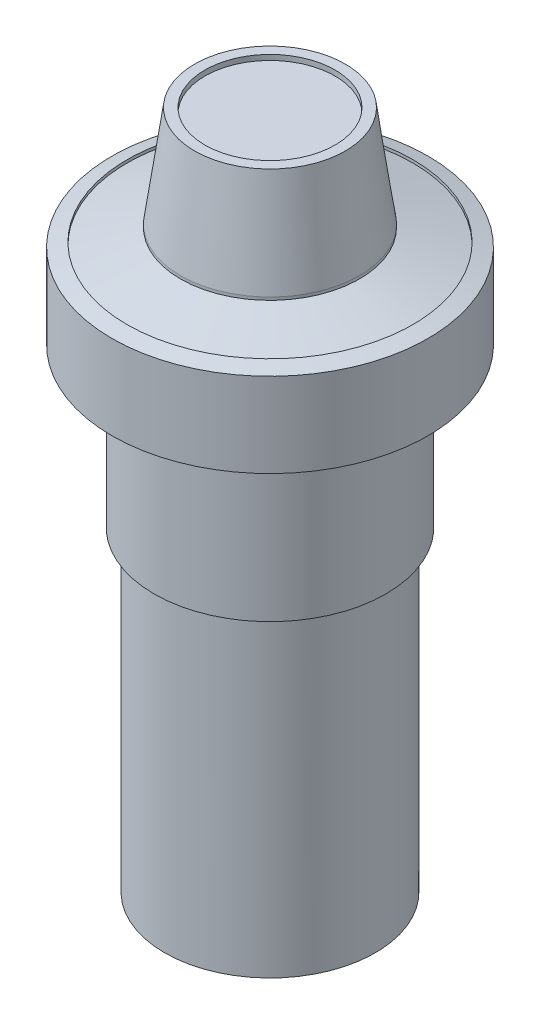
from build123d import *

# Parameters (mm, degrees)
SKETCH1_R           = 11
BOSS_EXTRUDE1_DEPTH = 15
SKETCH2_R           = 15
BOSS_EXTRUDE2_DEPTH = 8
SKETCH4_R           = 6.177060042
CUT_EXTRUDE1_DEPTH  = 0.5
SKETCH5_R           = 10
BOSS_EXTRUDE3_DEPTH = 30


with BuildPart() as part:
    # Sketch1 → Boss-Extrude1 (new body)
    with BuildSketch(Plane(origin=(0, 0, 0), x_dir=(1, 0, 0), z_dir=(0, 1, 0))):
        Circle(SKETCH1_R)
    extrude(amount=BOSS_EXTRUDE1_DEPTH)

    # Sketch2 → Boss-Extrude2 (add)
    with BuildSketch(Plane(origin=(0, 15, 0), x_dir=(1, 0, 0), z_dir=(0, 1, 0))):
        Circle(SKETCH2_R)
    extrude(amount=BOSS_EXTRUDE2_DEPTH)

    # Sketch3 → Revolve1 (revolve)
    with BuildSketch(Plane.XY):
        Polygon((-13.565724674, 23.42261725), (-15, 23), (0, 23), (0, 34.488010938), (-7.151825625, 34.488010938), (-8.49615375, 24.916394688), (-8.49615375, 24.638921263), (-13.565724674, 23.145143825), align=None)
    revolve(axis=Axis((0, 31.369169688, 0), (0, -1, 0)))

    # Sketch4 → Cut-Extrude1 (cut)
    with BuildSketch(Plane(origin=(0, 34.488010938, 0), x_dir=(1, 0, 0), z_dir=(0, 1, 0))):
        Circle(SKETCH4_R)
    extrude(amount=-CUT_EXTRUDE1_DEPTH, mode=Mode.SUBTRACT)

    # Sketch5 → Boss-Extrude3 (add)
    with BuildSketch(Plane.XZ):
        Circle(SKETCH5_R)
    extrude(amount=BOSS_EXTRUDE3_DEPTH)


solid = part.part
